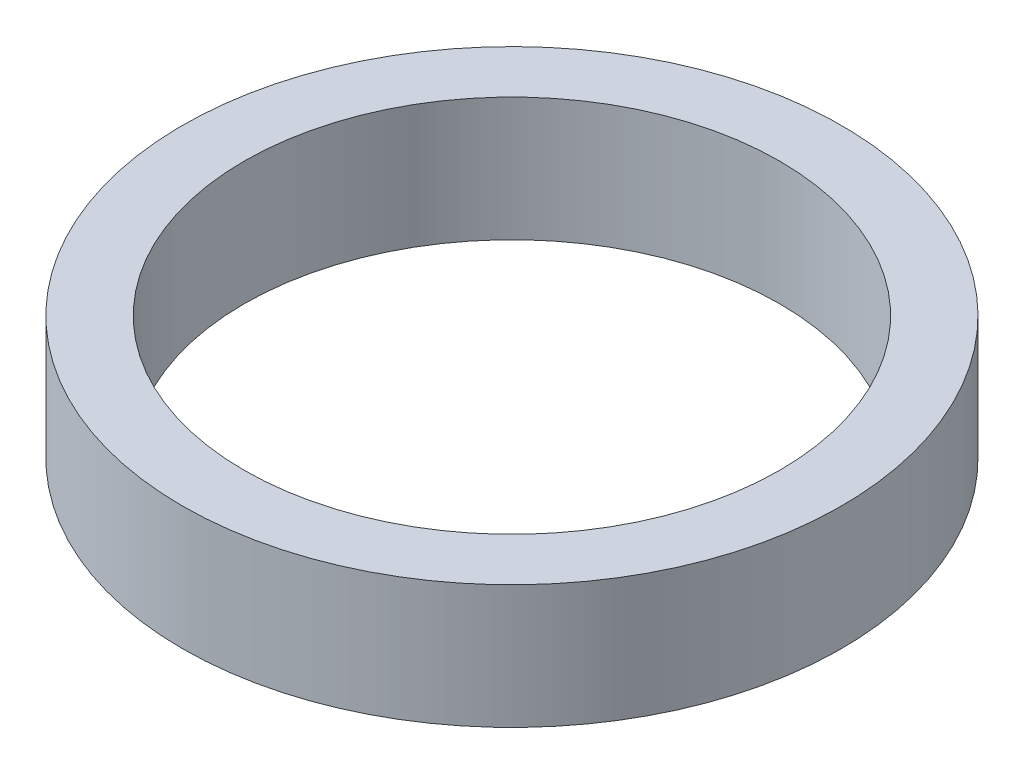
from build123d import *

# Parameters (mm, degrees)
SKETCH1_R           = 8
SKETCH1_R_2         = 6.5
BOSS_EXTRUDE1_DEPTH = 3


with BuildPart() as part:
    # Sketch1 → Boss-Extrude1 (new body)
    with BuildSketch(Plane(origin=(0, 0, 0), x_dir=(1, 0, 0), z_dir=(0, 1, 0))):
        Circle(SKETCH1_R)
        Circle(SKETCH1_R_2, mode=Mode.SUBTRACT)
    extrude(amount=BOSS_EXTRUDE1_DEPTH)


solid = part.part
